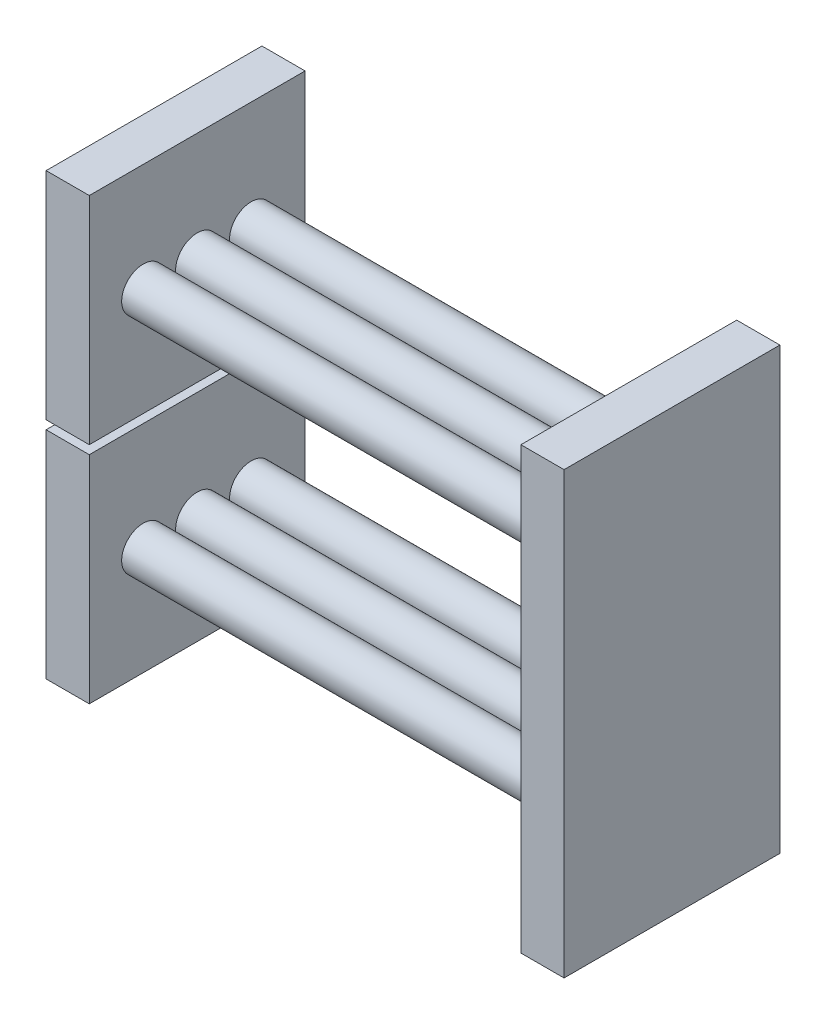
from build123d import *

# Parameters (mm, degrees)
BASEPLATESKETCH_W   = 50
BASEPLATESKETCH_H   = 50
BOSS_EXTRUDE1_DEPTH = 10
SKETCH2_R           = 5
BOSS_EXTRUDE3_DEPTH = 100
LPATTERN1_COUNT     = 2
LPATTERN1_PITCH     = 12.5
LPATTERN1_COL_COUNT = 2
LPATTERN1_COL_PITCH = 12.5
SKETCH7_W           = 50
SKETCH7_H           = 51
BOSS_EXTRUDE4_DEPTH = 10


with BuildPart() as part:
    # baseplatesketch → Boss-Extrude1 (new body)
    with BuildSketch(Plane(origin=(0, 0, 0), x_dir=(0, 0, -1), z_dir=(1, 0, 0))):
        Rectangle(BASEPLATESKETCH_W, BASEPLATESKETCH_H)
    extrude(amount=BOSS_EXTRUDE1_DEPTH)

    # Sketch2 → Boss-Extrude3 (add)
    with BuildSketch(Plane(origin=(10, 0, 0), x_dir=(0, 0, -1), z_dir=(1, 0, 0))):
        Circle(SKETCH2_R)
    boss_extrude3 = extrude(amount=BOSS_EXTRUDE3_DEPTH)

    # LPattern1: Boss-Extrude3 ×2
    with Locations(*[(0, 0, -i * LPATTERN1_PITCH) for i in range(1, LPATTERN1_COUNT)]):
        add(boss_extrude3)

    # LPattern1 col: Boss-Extrude3 ×2
    with Locations(*[(0, 0, i * LPATTERN1_COL_PITCH) for i in range(1, LPATTERN1_COL_COUNT)]):
        add(boss_extrude3)

    # Sketch7 → Boss-Extrude4 (add)
    with BuildSketch(Plane(origin=(110, 0, 0), x_dir=(0, 0, -1), z_dir=(1, 0, 0))):
        with Locations((0, -0.5)):
            Rectangle(SKETCH7_W, SKETCH7_H)
    extrude(amount=BOSS_EXTRUDE4_DEPTH)

    # Mirror8: part across plane


with BuildPart() as part_1:
    add(part.part)
    add(part.part.mirror(Plane(origin=(0, -26, 0), x_dir=(0, 0, 1), z_dir=(0, -1, 0))))


solid = part_1.part
